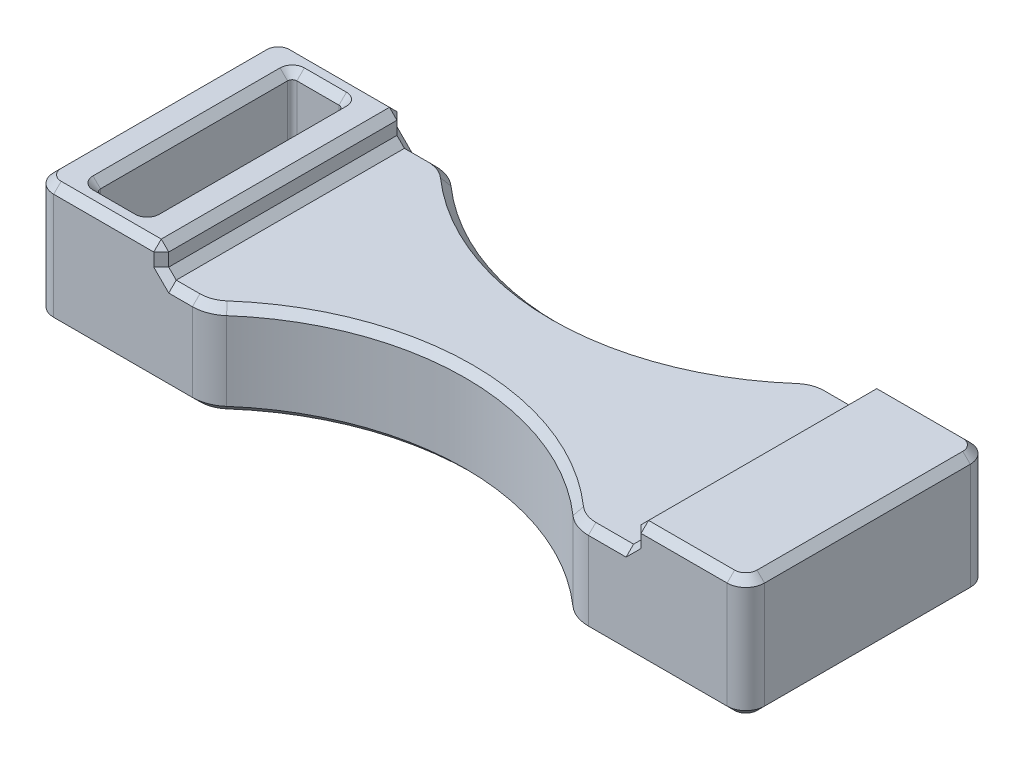
from build123d import *

# Parameters (mm, degrees)
BOSS_EXTRUDE1_DEPTH = 3.25
SKETCH2_W           = 25.25
SKETCH2_H           = 13
CUT_EXTRUDE1_DEPTH  = 1.5
FILLET1_R           = 2
CHAMFER1_SIZE       = 0.4


with BuildPart() as part:
    # Sketch1 → Boss-Extrude1 (new body, symmetric)
    with BuildSketch(Plane(origin=(0, 0, 0), x_dir=(1, 0, 0), z_dir=(0, 1, 0))):
        with BuildLine():
            Line((18, 6.5), (9.797958971, 6.5))
            ThreePointArc((9.797958971, 6.5), (0, 2.5), (-9.797958971, 6.5))
            Line((-9.797958971, 6.5), (-18, 6.5))
            ThreePointArc((-18, 6.5), (-18.707106781, 6.207106781), (-19, 5.5))
            Line((-19, 5.5), (-19, -5.5))
            ThreePointArc((-19, -5.5), (-18.707106781, -6.207106781), (-18, -6.5))
            Line((-18, -6.5), (-9.797958971, -6.5))
            ThreePointArc((-9.797958971, -6.5), (0, -2.5), (9.797958971, -6.5))
            Line((9.797958971, -6.5), (18, -6.5))
            ThreePointArc((18, -6.5), (18.707106781, -6.207106781), (19, -5.5))
            Line((19, -5.5), (19, 5.5))
            ThreePointArc((19, 5.5), (18.707106781, 6.207106781), (18, 6.5))
        make_face()
        with BuildLine():
            Line((-16.75, -5.25), (-14.5, -5.25))
            ThreePointArc((-14.5, -5.25), (-14.323223305, -5.176776695), (-14.25, -5))
            Line((-14.25, -5), (-14.25, 5))
            ThreePointArc((-14.25, 5), (-14.323223305, 5.176776695), (-14.5, 5.25))
            Line((-14.5, 5.25), (-16.75, 5.25))
            ThreePointArc((-16.75, 5.25), (-16.926776695, 5.176776695), (-17, 5))
            Line((-17, 5), (-17, -5))
            ThreePointArc((-17, -5), (-16.926776695, -5.176776695), (-16.75, -5.25))
        make_face(mode=Mode.SUBTRACT)
    extrude(amount=BOSS_EXTRUDE1_DEPTH, both=True)

    # Sketch2 → Cut-Extrude1 (cut)
    with BuildSketch(Plane(origin=(0, 3.25, 0), x_dir=(1, 0, 0), z_dir=(0, 1, 0))):
        with Locations((0.375, 0)):
            Rectangle(SKETCH2_W, SKETCH2_H)
    extrude(amount=-CUT_EXTRUDE1_DEPTH, mode=Mode.SUBTRACT)

    # Fillet1
    fillet1_edges = [part.edges().sort_by_distance(p)[0] for p in [
        (9.797958971, -0.75, 6.5),
        (-9.797958971, -0.75, 6.5),
        (-9.797958971, -0.75, -6.5),
        (9.797958971, -0.75, -6.5),
    ]]
    fillet(fillet1_edges, radius=FILLET1_R)

    # Chamfer1
    chamfer1_edges = [part.edges().sort_by_distance(p)[0] for p in [
        (-9.875898463, 1.75, -6.370828693),
        (19, -3.25, 0),
        (18.707106781, -3.25, 6.207106781),
        (-14.291502622, -3.25, 6.5),
        (-18.707106781, -3.25, 6.207106781),
        (-19, -3.25, 0),
        (-18.707106781, -3.25, -6.207106781),
        (14.291502622, -3.25, -6.5),
        (18.707106781, -3.25, -6.207106781),
        (-18.707106781, 3.25, -6.207106781),
        (-19, 3.25, 0),
        (-18.707106781, 3.25, 6.207106781),
        (-15.125, 3.25, 6.5),
        (-16.926776695, -3.25, 5.176776695),
        (-15.625, -3.25, 5.25),
        (-14.323223305, -3.25, 5.176776695),
        (-14.25, -3.25, 0),
        (-14.323223305, -3.25, -5.176776695),
        (-15.625, -3.25, -5.25),
        (-16.926776695, -3.25, -5.176776695),
        (-17, -3.25, 0),
        (-16.926776695, 3.25, 5.176776695),
        (-15.625, 3.25, 5.25),
        (-14.323223305, 3.25, 5.176776695),
        (-14.25, 3.25, 0),
        (-14.323223305, 3.25, -5.176776695),
        (-15.625, 3.25, -5.25),
        (-16.926776695, 3.25, -5.176776695),
        (-17, 3.25, 0),
        (18.707106781, 3.25, 6.207106781),
        (19, 3.25, 0),
        (18.707106781, 3.25, -6.207106781),
        (15.5, 3.25, 6.5),
        (11.791502622, 1.75, 6.5),
        (-15.125, 3.25, -6.5),
        (11.791502622, 1.75, -6.5),
        (-12.25, 2.5, -6.5),
        (-11.416502622, 1.75, 6.5),
        (13, 2.5, 6.5),
        (-12.25, 3.25, 0),
        (13, 3.25, 0),
        (13, 1.75, 0),
        (13, 2.5, -6.5),
        (-12.25, 1.75, 0),
        (-12.25, 2.5, 6.5),
        (15.5, 3.25, -6.5),
        (-11.416502622, 1.75, -6.5),
        (-14.291502622, -3.25, -6.5),
        (14.291502622, -3.25, 6.5),
        (0, -3.25, 2.5),
        (0, -3.25, -2.5),
        (-9.875898463, -3.25, 6.370828693),
        (9.875898463, -3.25, 6.370828693),
        (9.875898463, -3.25, -6.370828693),
        (-9.875898463, -3.25, -6.370828693),
        (0, 1.75, -2.5),
        (0, 1.75, 2.5),
        (-9.875898463, 1.75, 6.370828693),
        (9.875898463, 1.75, 6.370828693),
        (9.875898463, 1.75, -6.370828693),
    ]]
    chamfer(chamfer1_edges, length=CHAMFER1_SIZE)


solid = part.part
